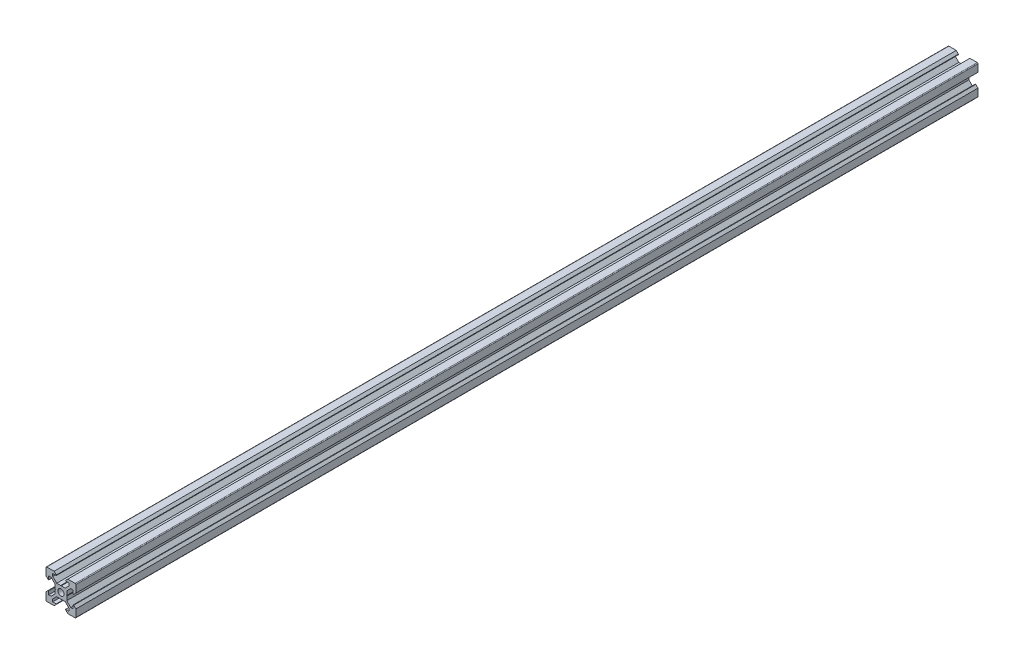
from build123d import *

# Parameters (mm, degrees)
SKETCH1_R           = 2.1
BOSS_EXTRUDE1_DEPTH = 604


with BuildPart() as part:
    # Sketch1 → Boss-Extrude1 (new body)
    with BuildSketch(Plane.XY):
        with BuildLine():
            Line((9.5, 10), (4.58, 10))
            Line((4.58, 10), (3.125, 8.545))
            Line((3.125, 8.545), (3.125, 8.2))
            Line((3.125, 8.2), (5.5, 8.2))
            Line((5.5, 8.2), (5.5, 6.560660172))
            Line((5.5, 6.560660172), (2.839339828, 3.9))
            Line((2.839339828, 3.9), (0.21, 3.9))
            Line((0.21, 3.9), (0, 3.69))
            Line((0, 3.69), (-0.21, 3.9))
            Line((-0.21, 3.9), (-2.839339828, 3.9))
            Line((-2.839339828, 3.9), (-5.5, 6.560660172))
            Line((-5.5, 6.560660172), (-5.5, 8.2))
            Line((-5.5, 8.2), (-3.125, 8.2))
            Line((-3.125, 8.2), (-3.125, 8.545))
            Line((-3.125, 8.545), (-4.58, 10))
            Line((-4.58, 10), (-9.5, 10))
            ThreePointArc((-9.5, 10), (-9.853553391, 9.853553391), (-10, 9.5))
            Line((-10, 9.5), (-10, 4.58))
            Line((-10, 4.58), (-8.545, 3.125))
            Line((-8.545, 3.125), (-8.2, 3.125))
            Line((-8.2, 3.125), (-8.2, 5.5))
            Line((-8.2, 5.5), (-6.560660172, 5.5))
            Line((-6.560660172, 5.5), (-3.9, 2.839339828))
            Line((-3.9, 2.839339828), (-3.9, 0.21))
            Line((-3.9, 0.21), (-3.69, 0))
            Line((-3.69, 0), (-3.9, -0.21))
            Line((-3.9, -0.21), (-3.9, -2.839339828))
            Line((-3.9, -2.839339828), (-6.560660172, -5.5))
            Line((-6.560660172, -5.5), (-8.2, -5.5))
            Line((-8.2, -5.5), (-8.2, -3.125))
            Line((-8.2, -3.125), (-8.545, -3.125))
            Line((-8.545, -3.125), (-10, -4.58))
            Line((-10, -4.58), (-10, -9.5))
            ThreePointArc((-10, -9.5), (-9.853553391, -9.853553391), (-9.5, -10))
            Line((-9.5, -10), (-4.58, -10))
            Line((-4.58, -10), (-3.125, -8.545))
            Line((-3.125, -8.545), (-3.125, -8.2))
            Line((-3.125, -8.2), (-5.5, -8.2))
            Line((-5.5, -8.2), (-5.5, -6.560660172))
            Line((-5.5, -6.560660172), (-2.839339828, -3.9))
            Line((-2.839339828, -3.9), (-0.21, -3.9))
            Line((-0.21, -3.9), (0, -3.69))
            Line((0, -3.69), (0.21, -3.9))
            Line((0.21, -3.9), (2.839339828, -3.9))
            Line((2.839339828, -3.9), (5.5, -6.560660172))
            Line((5.5, -6.560660172), (5.5, -8.2))
            Line((5.5, -8.2), (3.125, -8.2))
            Line((3.125, -8.2), (3.125, -8.545))
            Line((3.125, -8.545), (4.58, -10))
            Line((4.58, -10), (9.5, -10))
            ThreePointArc((9.5, -10), (9.853553391, -9.853553391), (10, -9.5))
            Line((10, -9.5), (10, -4.58))
            Line((10, -4.58), (8.545, -3.125))
            Line((8.545, -3.125), (8.2, -3.125))
            Line((8.2, -3.125), (8.2, -5.5))
            Line((8.2, -5.5), (6.560660172, -5.5))
            Line((6.560660172, -5.5), (3.9, -2.839339828))
            Line((3.9, -2.839339828), (3.9, -0.21))
            Line((3.9, -0.21), (3.69, 0))
            Line((3.69, 0), (3.9, 0.21))
            Line((3.9, 0.21), (3.9, 2.839339829))
            Line((3.9, 2.839339829), (6.560660171, 5.5))
            Line((6.560660171, 5.5), (8.2, 5.5))
            Line((8.2, 5.5), (8.2, 3.125))
            Line((8.2, 3.125), (8.545, 3.125))
            Line((8.545, 3.125), (10, 4.58))
            Line((10, 4.58), (10, 9.5))
            ThreePointArc((10, 9.5), (9.853553391, 9.853553391), (9.5, 10))
        make_face()
        Circle(SKETCH1_R, mode=Mode.SUBTRACT)
    extrude(amount=-BOSS_EXTRUDE1_DEPTH)


solid = part.part
